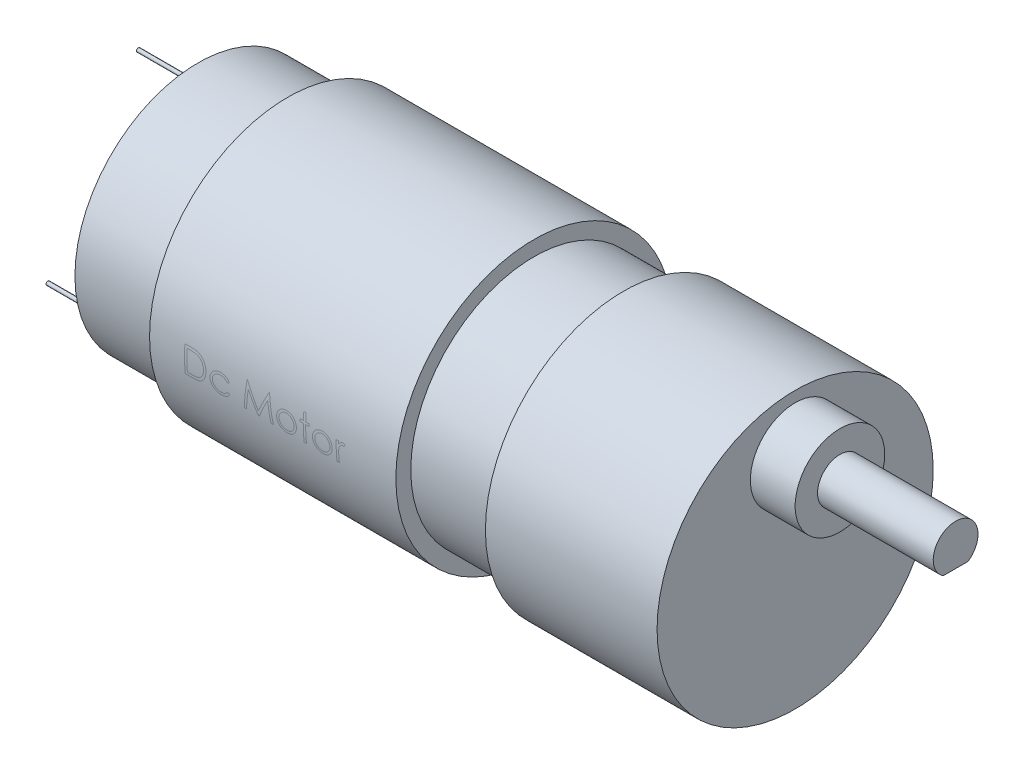
from build123d import *

# Parameters (mm, degrees)
SKETCH3_R           = 6
BOSS_EXTRUDE1_DEPTH = 6
SKETCH4_R           = 3
BOSS_EXTRUDE2_DEPTH = 3.5
BOSS_EXTRUDE3_DEPTH = 12
SKETCH6_R           = 0.25
BOSS_EXTRUDE4_DEPTH = 8


with BuildPart() as part:
    # Sketch2 → Revolve1 (revolve)
    with BuildSketch(Plane.XY):
        Polygon((88, 0), (88, 18.5), (65, 18.5), (65, 16.5), (53, 16.5), (53, 18.5), (20, 18.5), (20, 16.5), (8, 16.5), (8, 8), (4, 8), (4, 2), (0, 2), (0, 0), align=None)
    revolve(axis=Axis((88, 0, 0), (-1, 0, 0)))

    # Sketch3 → Boss-Extrude1 (add)
    with BuildSketch(Plane(origin=(88, 0, 0), x_dir=(0, 0, -1), z_dir=(1, 0, 0))):
        with Locations((0, 11.056321537)):
            Circle(SKETCH3_R)
    extrude(amount=BOSS_EXTRUDE1_DEPTH)

    # Sketch4 → Boss-Extrude2 (add)
    with BuildSketch(Plane(origin=(94, 0, 0), x_dir=(0, 0, -1), z_dir=(1, 0, 0))):
        with Locations((0, 11.056321537)):
            Circle(SKETCH4_R)
    extrude(amount=BOSS_EXTRUDE2_DEPTH)

    # Sketch5 → Boss-Extrude3 (add)
    with BuildSketch(Plane(origin=(97.5, 0, 0), x_dir=(0, 0, -1), z_dir=(1, 0, 0))):
        with BuildLine():
            Line((1.658312395, 8.556321537), (-1.658312395, 8.556321537))
            ThreePointArc((-1.658312395, 8.556321537), (0, 14.056321537), (1.658312395, 8.556321537))
        make_face()
    extrude(amount=BOSS_EXTRUDE3_DEPTH)

    # Sketch6 → Boss-Extrude4 (add)
    with BuildSketch(Plane.ZY.offset(-8)):
        with Locations((0, 14)):
            Circle(SKETCH6_R)
        with Locations((12.124355653, -7)):
            Circle(SKETCH6_R)
        with Locations((-12.124355653, -7)):
            Circle(SKETCH6_R)
    extrude(amount=BOSS_EXTRUDE4_DEPTH)


solid = part.part
